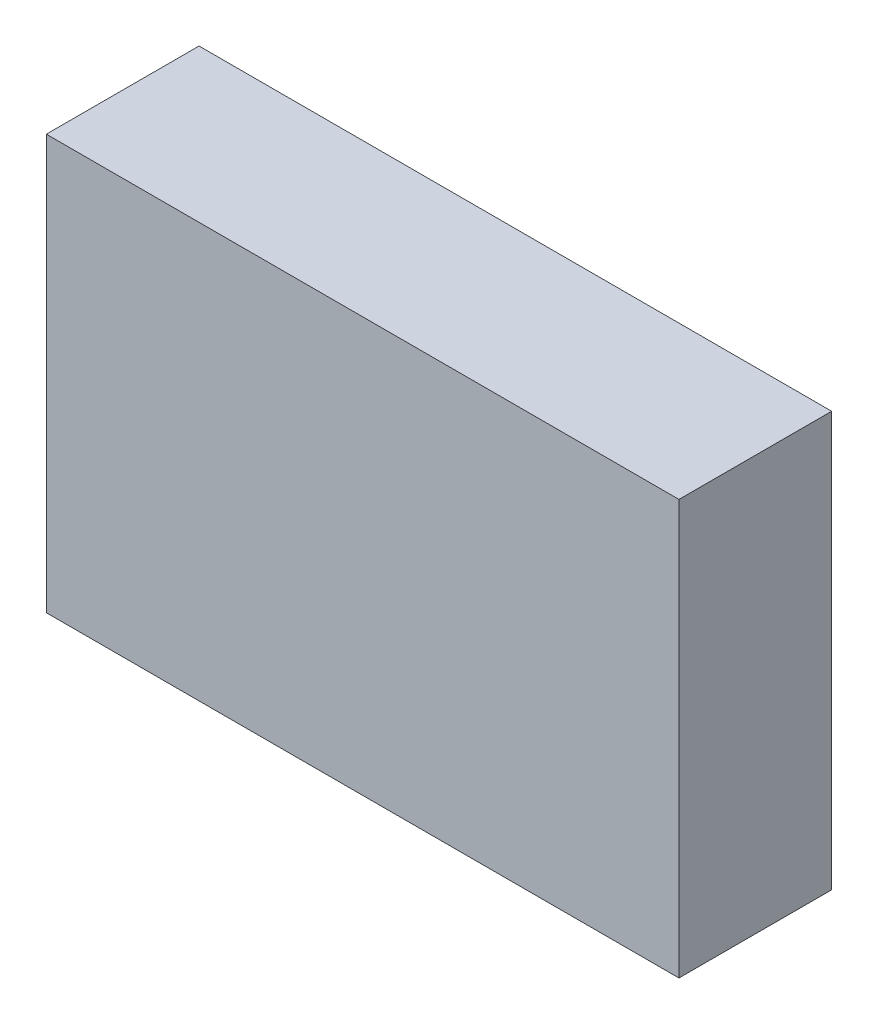
from build123d import *

# Parameters (mm, degrees)
ESQUISSE1_W        = 290
ESQUISSE1_H        = 190
BOSS_EXTRU_1_DEPTH = 70


with BuildPart() as part:
    # Esquisse1 → Boss.-Extru.1 (new body)
    with BuildSketch(Plane.XY):
        with Locations((145, 95)):
            Rectangle(ESQUISSE1_W, ESQUISSE1_H)
    extrude(amount=BOSS_EXTRU_1_DEPTH)


solid = part.part
